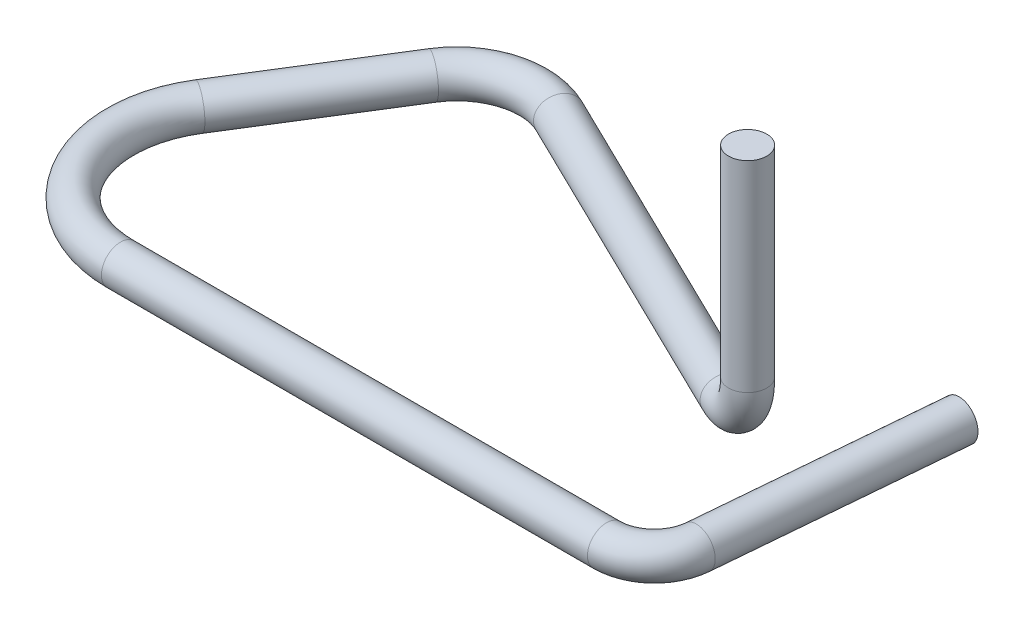
from build123d import *

# Parameters (mm, degrees)
SKETCH4_R = 0.508


with BuildPart() as part:
    # Sweep1: sweep along a curve in space
    with BuildLine() as sweep1_path:
        Line((15.748, 6.604, -4.969858904), (15.748, 1.27, -4.969858904))
        ThreePointArc((15.748, 1.27, -4.969858904), (15.413671635, 0.371974388, -5.132921743), (14.606531561, 0, -5.52659026))
        Line((14.606531561, 0, -5.52659026), (5.97077017, 0, -9.738532518))
        ThreePointArc((5.97077017, 0, -9.738532518), (4.519904893, 0, -9.865466782), (3.356766269, 0, -8.988978961))
        Line((3.356766269, 0, -8.988978961), (0.971149403, 0, -5.171193917))
        ThreePointArc((0.971149403, 0, -5.171193917), (0.890159133, 0, -2.078300277), (3.556, 0, -0.508))
        Line((3.556, 0, -0.508), (16.463402457, 0, -0.508))
        ThreePointArc((16.463402457, 0, -0.508), (17.321402021, 0, -0.841657782), (17.728569724, 0, -1.667312207))
        Line((17.728569724, 0, -1.667312207), (18.289933093, 0, -8.083724883))
    # Sketch4 → Sweep1 (sweep)
    with BuildSketch(Plane(origin=(0, 6.604, 0), x_dir=(1, 0, 0), z_dir=(0, 1, 0))):
        with Locations((15.748, 4.969858904)):
            Circle(SKETCH4_R)
    sweep(path=sweep1_path.line)


solid = part.part
